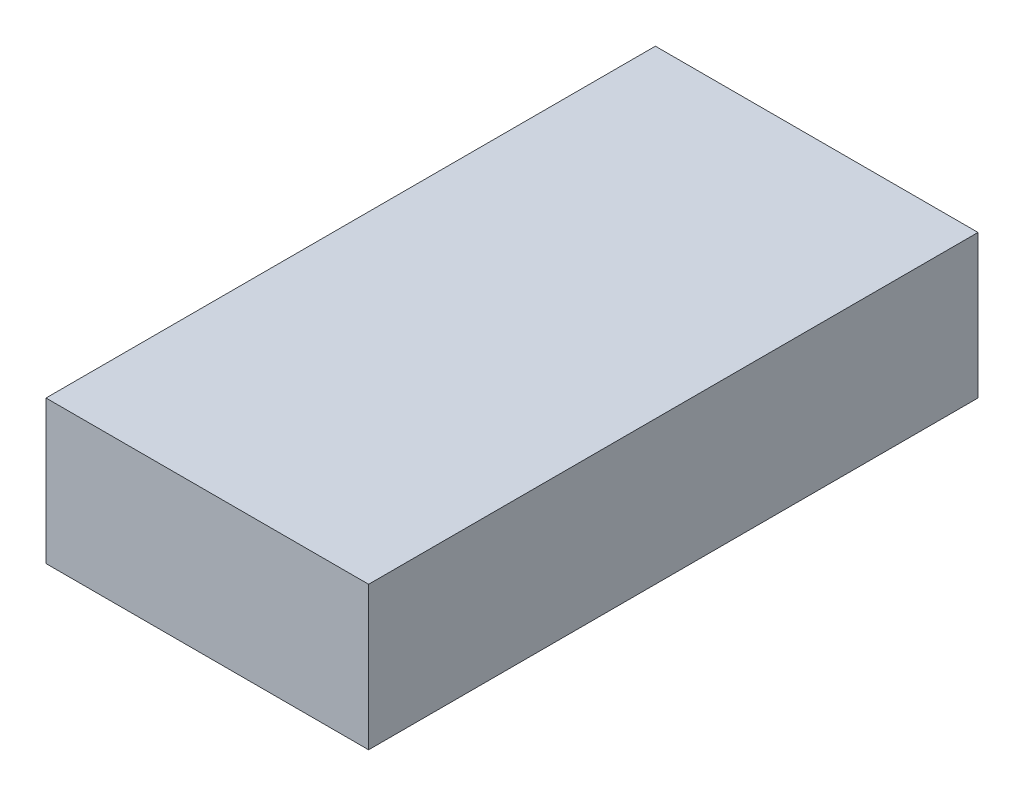
from build123d import *

# Parameters (mm, degrees)
SKETCH1_W           = 36.000000104
SKETCH1_H           = 68
BOSS_EXTRUDE1_DEPTH = 16


with BuildPart() as part:
    # Sketch1 → Boss-Extrude1 (new body)
    with BuildSketch(Plane(origin=(0, 0, 0), x_dir=(1, 0, 0), z_dir=(0, 1, 0))):
        Rectangle(SKETCH1_W, SKETCH1_H)
    extrude(amount=BOSS_EXTRUDE1_DEPTH)


solid = part.part
